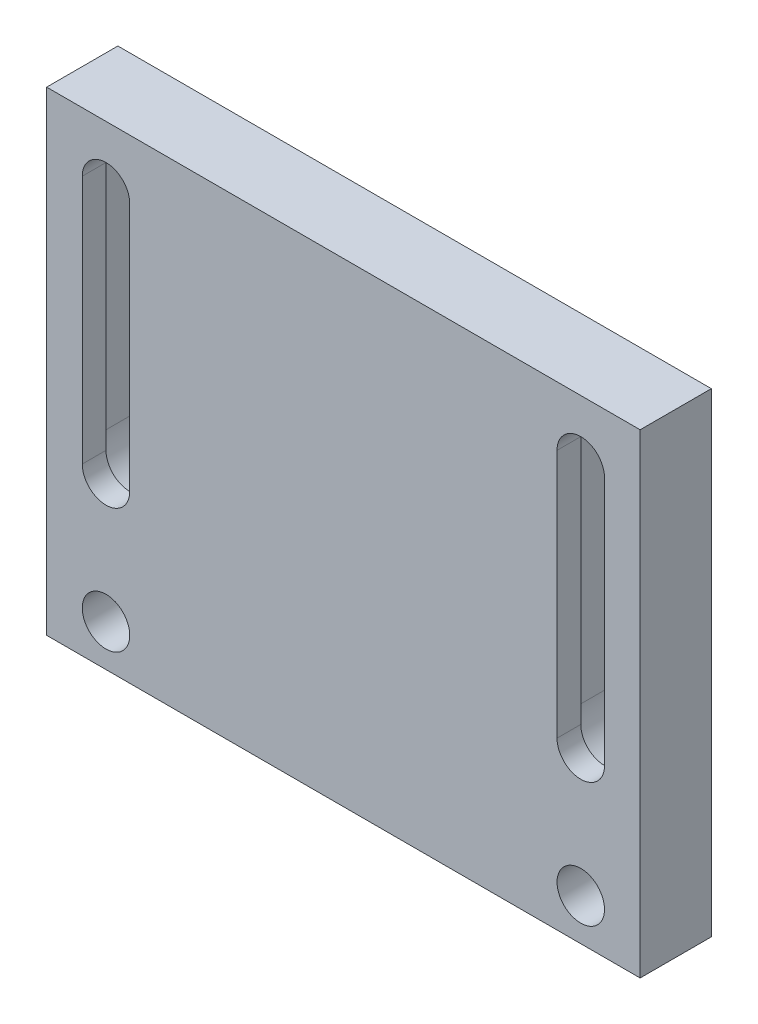
from build123d import *

# Parameters (mm, degrees)
SKETCH1_W           = 50
SKETCH1_H           = 40
BOSS_EXTRUDE1_DEPTH = 6
CUT_EXTRUDE3_DEPTH  = 4
SKETCH7_R           = 2
CUT_EXTRUDE4_DEPTH  = 6


with BuildPart() as part:
    # Sketch1 → Boss-Extrude1 (new body)
    with BuildSketch(Plane.XY):
        Rectangle(SKETCH1_W, SKETCH1_H)
    extrude(amount=BOSS_EXTRUDE1_DEPTH)

    # Sketch6 → Cut-Extrude3 (cut)
    with BuildSketch(Plane(origin=(0, 0, 0), x_dir=(-1, 0, 0), z_dir=(0, 0, -1))):
        with BuildLine():
            Line((-16.5, 15), (-16.5, -6))
            ThreePointArc((-16.5, -6), (-20, -9.5), (-23.5, -6))
            Line((-23.5, -6), (-23.5, 15))
            ThreePointArc((-23.5, 15), (-20, 18.5), (-16.5, 15))
        make_face()
        with BuildLine():
            Line((23.5, 15), (23.5, -6))
            ThreePointArc((23.5, -6), (20, -9.5), (16.5, -6))
            Line((16.5, -6), (16.5, 15))
            ThreePointArc((16.5, 15), (20, 18.5), (23.5, 15))
        make_face()
    extrude(amount=-CUT_EXTRUDE3_DEPTH, mode=Mode.SUBTRACT)

    # Sketch7 → Cut-Extrude4 (cut)
    with BuildSketch(Plane(origin=(0, 0, 0), x_dir=(-1, 0, 0), z_dir=(0, 0, -1))):
        with Locations((-20, -16.5)):
            Circle(SKETCH7_R)
        with Locations((20, -16.5)):
            Circle(SKETCH7_R)
        with BuildLine():
            Line((-22, 15), (-22, -6))
            ThreePointArc((-22, -6), (-20, -8), (-18, -6))
            Line((-18, -6), (-18, 15))
            ThreePointArc((-18, 15), (-20, 17), (-22, 15))
        make_face()
        with BuildLine():
            Line((18, 15), (18, -6))
            ThreePointArc((18, -6), (20, -8), (22, -6))
            Line((22, -6), (22, 15))
            ThreePointArc((22, 15), (20, 17), (18, 15))
        make_face()
    extrude(amount=-CUT_EXTRUDE4_DEPTH, mode=Mode.SUBTRACT)


solid = part.part
